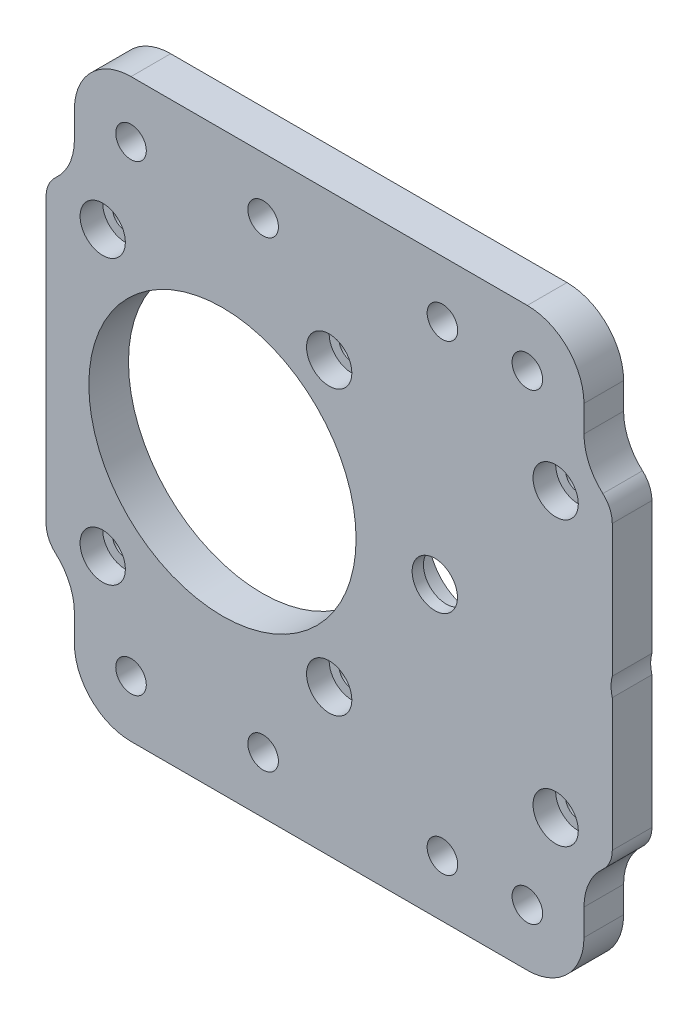
from build123d import *

# Parameters (mm, degrees)
SKETCH2_R                      = 2.15
SKETCH2_R_2                    = 23.6
BOSS_EXTRUDE1_DEPTH            = 7
CUT_EXTRUDE1_START             = -7
SKETCH3_R                      = 8.1
SKETCH3_R_2                    = 23.6
CUT_EXTRUDE1_DEPTH             = 5
SKETCH4_R                      = 4
CUT_EXTRUDE2_DEPTH             = 5
SKETCH5_R                      = 6.365
CUT_EXTRUDE3_DEPTH             = 10
CBORE_FOR_M4_SHCS1_D           = 4.5
CBORE_FOR_M4_SHCS1_CBORE_D     = 8
CBORE_FOR_M4_SHCS1_CBORE_DEPTH = 4
SKETCH9_W                      = 90
SKETCH9_H                      = 20.85
SKETCH9_R                      = 2.7
BOSS_EXTRUDE3_DEPTH            = 7
FILLET2_R                      = 10
SKETCH10_W                     = 55
SKETCH10_H                     = 101.7
SKETCH10_R                     = 23.6
SKETCH10_R_2                   = 2.25
SKETCH10_R_3                   = 2.7
BOSS_EXTRUDE4_DEPTH            = 7


with BuildPart() as part:
    # Sketch2 → Boss-Extrude1 (new body)
    with BuildSketch(Plane.XY.offset(-75.526253649)):
        with BuildLine():
            Line((63.85, 30), (-26.15, 30))
            ThreePointArc((-26.15, 30), (-29.685533906, 28.535533906), (-31.15, 25))
            Line((-31.15, 25), (-31.15, -25))
            ThreePointArc((-31.15, -25), (-29.685533906, -28.535533906), (-26.15, -30))
            Line((-26.15, -30), (63.85, -30))
            ThreePointArc((63.85, -30), (67.385533906, -28.535533906), (68.85, -25))
            Line((68.85, -25), (68.85, 25))
            ThreePointArc((68.85, 25), (67.385533906, 28.535533906), (63.85, 30))
        make_face()
        with Locations((58.85, 25)):
            Circle(SKETCH2_R, mode=Mode.SUBTRACT)
        with Locations((18.85, 25)):
            Circle(SKETCH2_R, mode=Mode.SUBTRACT)
        with Locations((-21.15, 25)):
            Circle(SKETCH2_R, mode=Mode.SUBTRACT)
        with Locations((-21.15, -25)):
            Circle(SKETCH2_R, mode=Mode.SUBTRACT)
        with Locations((18.85, -25)):
            Circle(SKETCH2_R, mode=Mode.SUBTRACT)
        with Locations((58.85, -25)):
            Circle(SKETCH2_R, mode=Mode.SUBTRACT)
        Circle(SKETCH2_R_2, mode=Mode.SUBTRACT)
    extrude(amount=BOSS_EXTRUDE1_DEPTH)

    # Sketch3 → Cut-Extrude1 (cut)
    with BuildSketch(Plane.XY.offset(-68.526253649).offset(CUT_EXTRUDE1_START)):
        with Locations((37.5, 0)):
            Circle(SKETCH3_R)
        Circle(SKETCH3_R_2)
    extrude(amount=CUT_EXTRUDE1_DEPTH, mode=Mode.SUBTRACT)

    # Sketch4 → Cut-Extrude2 (cut)
    with BuildSketch(Plane(origin=(0, 0, -70.526253649), x_dir=(-1, 0, 0), z_dir=(0, 0, -1))):
        with Locations((-37.5, 0)):
            Circle(SKETCH4_R)
    extrude(amount=-CUT_EXTRUDE2_DEPTH, mode=Mode.SUBTRACT)

    # Sketch5 → Cut-Extrude3 (cut)
    with BuildSketch(Plane.XY.offset(-68.526253649)):
        with Locations((75, 0)):
            Circle(SKETCH5_R)
    extrude(amount=-CUT_EXTRUDE3_DEPTH, mode=Mode.SUBTRACT)

    # CBORE for M4 SHCS1 (through all)
    with Locations(Plane(origin=(-21.15, 25, -68.526253649), x_dir=(1, 0, 0), z_dir=(0, 0, 1))):
        with Locations((0, 0), (40, 0), (80, 0), (80, -50), (40, -50), (0, -50)):
            CounterBoreHole(CBORE_FOR_M4_SHCS1_D / 2, CBORE_FOR_M4_SHCS1_CBORE_D / 2, CBORE_FOR_M4_SHCS1_CBORE_DEPTH)

    # Sketch9 → Boss-Extrude3 (add)
    with BuildSketch(Plane.XY.offset(-68.526253649)):
        with Locations((18.85, 40.425)):
            Rectangle(SKETCH9_W, SKETCH9_H)
        with Locations((-16.15, 40.85)):
            Circle(SKETCH9_R, mode=Mode.SUBTRACT)
        with Locations((7.183333333, 40.85)):
            Circle(SKETCH9_R, mode=Mode.SUBTRACT)
        with Locations((53.85, 40.85)):
            Circle(SKETCH9_R, mode=Mode.SUBTRACT)
        with Locations((38.85, 40.85)):
            Circle(SKETCH9_R, mode=Mode.SUBTRACT)
        with Locations((18.85, -40.425)):
            Rectangle(SKETCH9_W, SKETCH9_H)
        with Locations((53.85, -40.85)):
            Circle(SKETCH9_R, mode=Mode.SUBTRACT)
        with Locations((7.183333333, -40.85)):
            Circle(SKETCH9_R, mode=Mode.SUBTRACT)
        with Locations((-16.15, -40.85)):
            Circle(SKETCH9_R, mode=Mode.SUBTRACT)
        with Locations((38.85, -40.85)):
            Circle(SKETCH9_R, mode=Mode.SUBTRACT)
    extrude(amount=-BOSS_EXTRUDE3_DEPTH)

    # Fillet2
    fillet2_edges = [part.edges().sort_by_distance(p)[0] for p in [
        (63.85, 50.85, -72.026253649),
        (-26.15, 50.85, -72.026253649),
        (63.85, -30, -72.026253649),
        (-26.15, -30, -72.026253649),
        (-26.15, 30, -72.026253649),
        (63.85, 30, -72.026253649),
        (-26.15, -50.85, -72.026253649),
        (63.85, -50.85, -72.026253649),
    ]]
    fillet(fillet2_edges, radius=FILLET2_R)


with BuildPart() as body_2:
    # Sketch10 → Boss-Extrude4 (new body)
    with BuildSketch(Plane.XY.offset(-68.526253649)):
        Rectangle(SKETCH10_W, SKETCH10_H)
        Circle(SKETCH10_R, mode=Mode.SUBTRACT)
        with Locations((-21.15, 25)):
            Circle(SKETCH10_R_2, mode=Mode.SUBTRACT)
        with Locations((18.85, 25)):
            Circle(SKETCH10_R_2, mode=Mode.SUBTRACT)
        with Locations((18.85, -25)):
            Circle(SKETCH10_R_2, mode=Mode.SUBTRACT)
        with Locations((-21.15, -25)):
            Circle(SKETCH10_R_2, mode=Mode.SUBTRACT)
        with Locations((-16.15, -40.85)):
            Circle(SKETCH10_R_3, mode=Mode.SUBTRACT)
        with Locations((7.183333333, -40.85)):
            Circle(SKETCH10_R_3, mode=Mode.SUBTRACT)
        with Locations((7.183333333, 40.85)):
            Circle(SKETCH10_R_3, mode=Mode.SUBTRACT)
        with Locations((-16.15, 40.85)):
            Circle(SKETCH10_R_3, mode=Mode.SUBTRACT)
    extrude(amount=BOSS_EXTRUDE4_DEPTH)


solid = part.part
